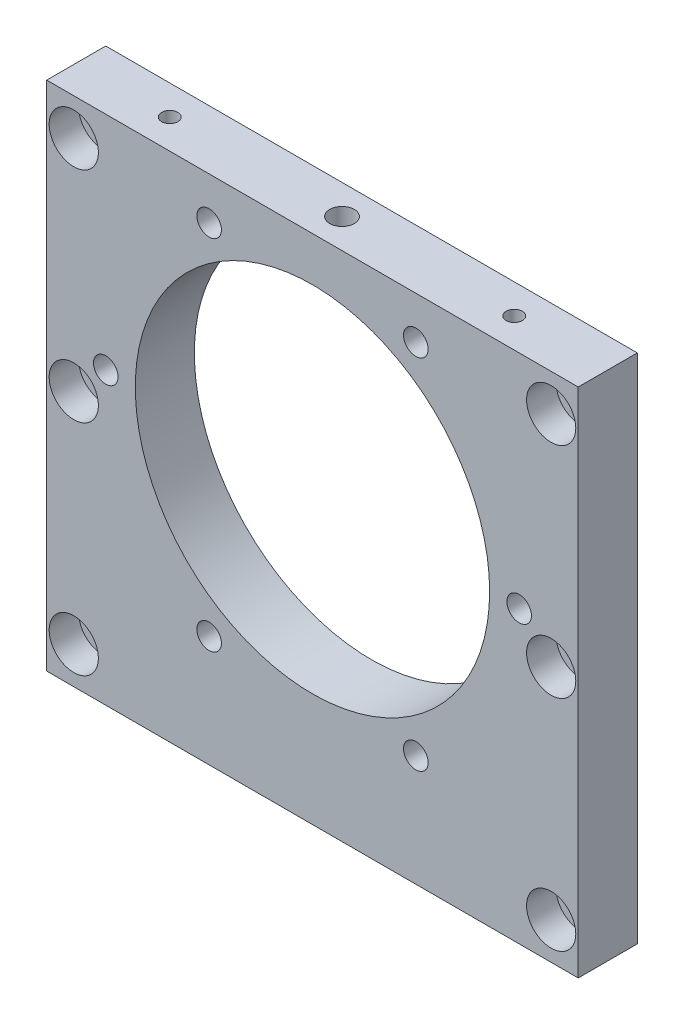
from build123d import *

# Parameters (mm, degrees)
CROQUIS1_W                = 108
CROQUIS1_H                = 104
CROQUIS1_R                = 36
CROQUIS1_R_2              = 3.25
SALIENTE_EXTRUIR1_DEPTH   = 6
TALADRO_ROSCADO_M61_D     = 5
CROQUIS4_R                = 5
CORTAR_EXTRUIR1_DEPTH     = 6
TALADRO_ROSCADO_M62_D     = 5
TALADRO_ROSCADO_M62_DEPTH = 27
TALADRO_ROSCADO_M62_TIP   = 1.502151548
TALADRO_ROSCADO_M41_D     = 3.3
TALADRO_ROSCADO_M41_DEPTH = 12
TALADRO_ROSCADO_M41_TIP   = 0.991420021


with BuildPart() as part:
    # Croquis1 → Saliente-Extruir1 (new body, symmetric)
    with BuildSketch(Plane.XY):
        Rectangle(CROQUIS1_W, CROQUIS1_H)
        with Locations((0, 7)):
            Circle(CROQUIS1_R, mode=Mode.SUBTRACT)
        with Locations((-48.5, 44.5)):
            Circle(CROQUIS1_R_2, mode=Mode.SUBTRACT)
        with Locations((-48.5, 0)):
            Circle(CROQUIS1_R_2, mode=Mode.SUBTRACT)
        with Locations((-48.5, -44.5)):
            Circle(CROQUIS1_R_2, mode=Mode.SUBTRACT)
        with Locations((48.5, -44.5)):
            Circle(CROQUIS1_R_2, mode=Mode.SUBTRACT)
        with Locations((48.5, 0)):
            Circle(CROQUIS1_R_2, mode=Mode.SUBTRACT)
        with Locations((48.5, 44.5)):
            Circle(CROQUIS1_R_2, mode=Mode.SUBTRACT)
    extrude(amount=SALIENTE_EXTRUIR1_DEPTH, both=True)

    # Taladro roscado M61 (through all)
    with Locations(Plane.XY.offset(6)):
        with Locations((-21, 43.373066959), (-42, 7), (-21, -29.373066959), (21, -29.373066959), (42, 7), (21, 43.373066959)):
            Hole(TALADRO_ROSCADO_M61_D / 2)

    # Croquis4 → Cortar-Extruir1 (cut)
    with BuildSketch(Plane.XY.offset(6)):
        with Locations((-48.5, 44.5)):
            Circle(CROQUIS4_R)
        with Locations((-48.5, 0)):
            Circle(CROQUIS4_R)
        with Locations((-48.5, -44.5)):
            Circle(CROQUIS4_R)
        with Locations((48.5, -44.5)):
            Circle(CROQUIS4_R)
        with Locations((48.5, 0)):
            Circle(CROQUIS4_R)
        with Locations((48.5, 44.5)):
            Circle(CROQUIS4_R)
    extrude(amount=-CORTAR_EXTRUIR1_DEPTH, mode=Mode.SUBTRACT)

    # Taladro roscado M62
    with Locations(Plane(origin=(0, 52, 0), x_dir=(-1, 0, 0), z_dir=(0, 1, 0))):
        with Locations((0, 0)):
            Hole(TALADRO_ROSCADO_M62_D / 2, depth=TALADRO_ROSCADO_M62_DEPTH)
            with Locations((0, 0, -(TALADRO_ROSCADO_M62_DEPTH + TALADRO_ROSCADO_M62_TIP / 2))):  # 118° drill point
                Cone(0, TALADRO_ROSCADO_M62_D / 2, TALADRO_ROSCADO_M62_TIP, mode=Mode.SUBTRACT)

    # Taladro roscado M41
    with Locations(Plane(origin=(0, 52, 0), x_dir=(-1, 0, 0), z_dir=(0, 1, 0))):
        with Locations((35, 0), (-35, 0)):
            Hole(TALADRO_ROSCADO_M41_D / 2, depth=TALADRO_ROSCADO_M41_DEPTH)
            with Locations((0, 0, -(TALADRO_ROSCADO_M41_DEPTH + TALADRO_ROSCADO_M41_TIP / 2))):  # 118° drill point
                Cone(0, TALADRO_ROSCADO_M41_D / 2, TALADRO_ROSCADO_M41_TIP, mode=Mode.SUBTRACT)


solid = part.part
